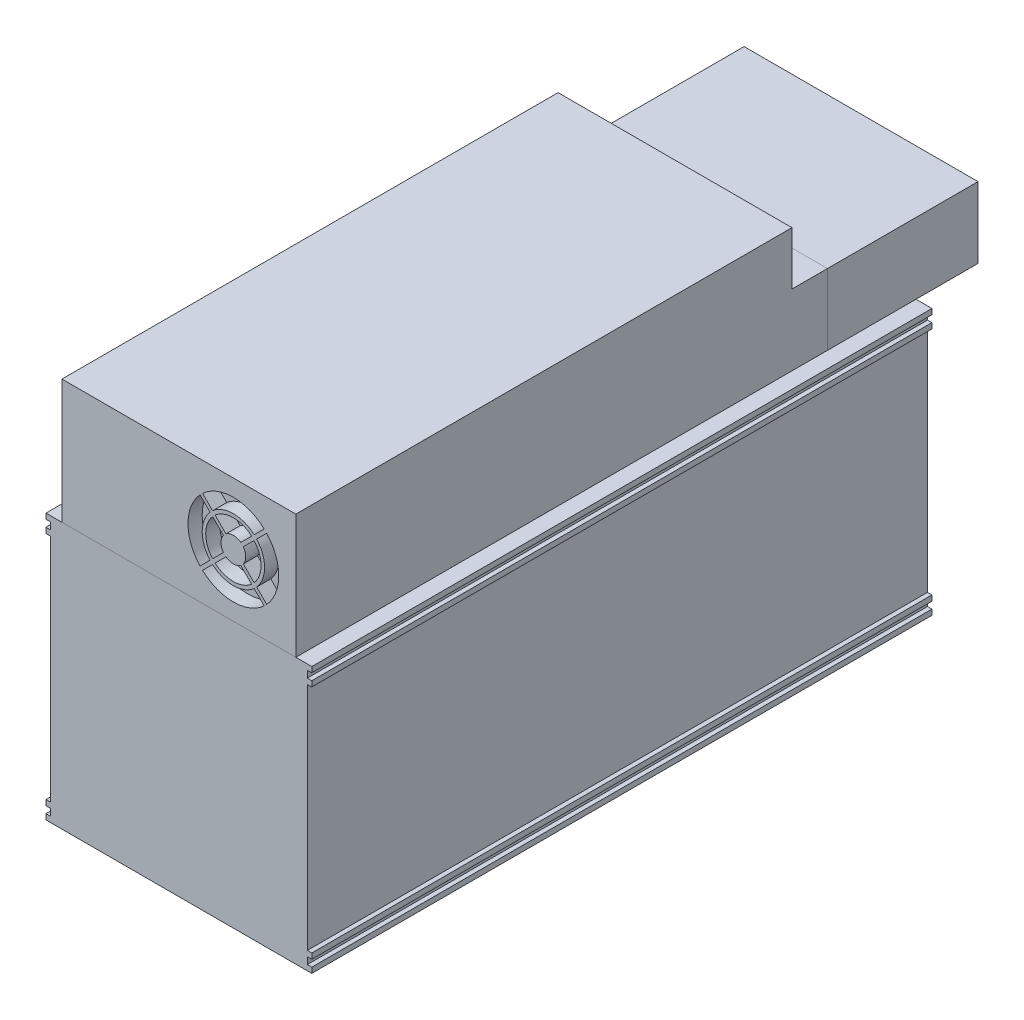
from build123d import *

# Parameters (mm, degrees)
SKETCH1_W               = 150
SKETCH1_H               = 150
BOSS_EXTRUDE1_DEPTH     = 350
SKETCH2_W               = 132
SKETCH2_H               = 70
BOSS_EXTRUDE2_DEPTH     = 300
SKETCH3_W               = 20
SKETCH3_H               = 30
CUT_EXTRUDE1_DEPTH      = 300
SKETCH4_W               = 132
SKETCH4_H               = 40
BOSS_EXTRUDE3_DEPTH     = 85
SKETCH5_W               = 5
SKETCH5_H               = 130
CUT_EXTRUDE2_DEPTH      = 448
SKETCH6_W               = 5
SKETCH6_H               = 3.857436254
CUT_EXTRUDE3_DEPTH      = 448
MIRROR2_COPY_1_SKETCH_W = 5
MIRROR2_COPY_1_SKETCH_H = 3.857436254
MIRROR2_COPY_1_DEPTH    = 448
CUT_EXTRUDE5_DEPTH      = 8


with BuildPart() as part:
    # Sketch1 → Boss-Extrude1 (new body)
    with BuildSketch(Plane.XY):
        Rectangle(SKETCH1_W, SKETCH1_H)
    extrude(amount=BOSS_EXTRUDE1_DEPTH)

    # Sketch5 → Cut-Extrude2 (cut)
    with BuildSketch(Plane.XY.offset(350)):
        with Locations((75, 0)):
            Rectangle(SKETCH5_W, SKETCH5_H)
    cut_extrude2 = extrude(amount=-CUT_EXTRUDE2_DEPTH, mode=Mode.SUBTRACT)

    # Sketch6 → Cut-Extrude3 (cut)
    with BuildSketch(Plane.XY.offset(350)):
        with Locations((75, 70)):
            Rectangle(SKETCH6_W, SKETCH6_H)
    cut_extrude3 = extrude(amount=-CUT_EXTRUDE3_DEPTH, mode=Mode.SUBTRACT)

    # Mirror1: Cut-Extrude3 across plane
    add(cut_extrude3.mirror(Plane.ZX), mode=Mode.SUBTRACT)

    # Mirror2: Cut-Extrude2, Cut-Extrude3 across plane
    add(cut_extrude2.mirror(Plane(origin=(0, 0, 0), x_dir=(0, 0, 1), z_dir=(1, 0, 0))), mode=Mode.SUBTRACT)
    add(cut_extrude3.mirror(Plane(origin=(0, 0, 0), x_dir=(0, 0, 1), z_dir=(1, 0, 0))), mode=Mode.SUBTRACT)

    # Mirror2 copy 1 sketch → Mirror2 copy 1 (cut)
    with BuildSketch(Plane(origin=(0, 0, 350), x_dir=(-1, 0, 0), z_dir=(0, 0, 1))):
        with Locations((75, 70)):
            Rectangle(MIRROR2_COPY_1_SKETCH_W, MIRROR2_COPY_1_SKETCH_H)
    extrude(amount=-MIRROR2_COPY_1_DEPTH, mode=Mode.SUBTRACT)


with BuildPart() as body_2:
    # Sketch2 → Boss-Extrude2 (new body)
    with BuildSketch(Plane.XY.offset(350)):
        with Locations((0, 110)):
            Rectangle(SKETCH2_W, SKETCH2_H)
    extrude(amount=-BOSS_EXTRUDE2_DEPTH)

    # Sketch3 → Cut-Extrude1 (cut)
    with BuildSketch(Plane.ZY.offset(66)):
        with Locations((60, 130)):
            Rectangle(SKETCH3_W, SKETCH3_H)
    extrude(amount=-CUT_EXTRUDE1_DEPTH, mode=Mode.SUBTRACT)

    # Sketch7 → Cut-Extrude5 (cut)
    with BuildSketch(Plane.XY.offset(350)):
        with BuildLine():
            Line((34.931688454, 104.396773358), (41.052524005, 98.275937807))
            ThreePointArc((41.052524005, 98.275937807), (30.742675374, 94.387613472), (20.432826744, 98.275937807))
            Line((20.432826744, 98.275937807), (26.553662294, 104.396773358))
            ThreePointArc((26.553662294, 104.396773358), (30.742675374, 103.004002617), (34.931688454, 104.396773358))
        make_face()
        with BuildLine():
            Line((36.345902017, 105.81098692), (42.466737568, 99.690151369))
            ThreePointArc((42.466737568, 99.690151369), (46.355061902, 110), (42.466737568, 120.309848631))
            Line((42.466737568, 120.309848631), (36.345902017, 114.18901308))
            ThreePointArc((36.345902017, 114.18901308), (37.738672758, 110), (36.345902017, 105.81098692))
        make_face()
        with BuildLine():
            Line((43.883529765, 121.726640828), (49.546665087, 127.38977615))
            ThreePointArc((49.546665087, 127.38977615), (56.355061902, 110), (49.546665087, 92.61022385))
            Line((49.546665087, 92.61022385), (43.883529765, 98.273359172))
            ThreePointArc((43.883529765, 98.273359172), (48.355061902, 110), (43.883529765, 121.726640828))
        make_face()
        with BuildLine():
            Line((34.931688454, 115.603226642), (41.052524005, 121.724062193))
            ThreePointArc((41.052524005, 121.724062193), (30.742675374, 125.612386528), (20.432826744, 121.724062193))
            Line((20.432826744, 121.724062193), (26.553662294, 115.603226642))
            ThreePointArc((26.553662294, 115.603226642), (30.742675374, 116.995997383), (34.931688454, 115.603226642))
        make_face()
        with BuildLine():
            Line((42.469316202, 123.14085439), (48.132451524, 128.803989713))
            ThreePointArc((48.132451524, 128.803989713), (30.742675374, 135.612386528), (13.352899224, 128.803989713))
            Line((13.352899224, 128.803989713), (19.016034546, 123.14085439))
            ThreePointArc((19.016034546, 123.14085439), (30.742675374, 127.612386528), (42.469316202, 123.14085439))
        make_face()
        with BuildLine():
            Line((42.469316202, 96.85914561), (48.132451524, 91.196010287))
            ThreePointArc((48.132451524, 91.196010287), (30.742675374, 84.387613472), (13.352899224, 91.196010287))
            Line((13.352899224, 91.196010287), (19.016034546, 96.85914561))
            ThreePointArc((19.016034546, 96.85914561), (30.742675374, 92.387613472), (42.469316202, 96.85914561))
        make_face()
        with BuildLine():
            Line((25.139448732, 105.81098692), (19.018613181, 99.690151369))
            ThreePointArc((19.018613181, 99.690151369), (15.130288846, 110), (19.018613181, 120.309848631))
            Line((19.018613181, 120.309848631), (25.139448732, 114.18901308))
            ThreePointArc((25.139448732, 114.18901308), (23.746677991, 110), (25.139448732, 105.81098692))
        make_face()
        with BuildLine():
            Line((17.601820984, 98.273359172), (11.938685662, 92.61022385))
            ThreePointArc((11.938685662, 92.61022385), (5.130288846, 110), (11.938685662, 127.38977615))
            Line((11.938685662, 127.38977615), (17.601820984, 121.726640828))
            ThreePointArc((17.601820984, 121.726640828), (13.130288846, 110), (17.601820984, 98.273359172))
        make_face()
    extrude(amount=-CUT_EXTRUDE5_DEPTH, mode=Mode.SUBTRACT)


with BuildPart() as body_3:
    # Sketch4 → Boss-Extrude3 (new body)
    with BuildSketch(Plane(origin=(0, 0, 50), x_dir=(-1, 0, 0), z_dir=(0, 0, -1))):
        with Locations((0, 95)):
            Rectangle(SKETCH4_W, SKETCH4_H)
    extrude(amount=BOSS_EXTRUDE3_DEPTH)


solid = Compound([part.part, body_2.part, body_3.part])
